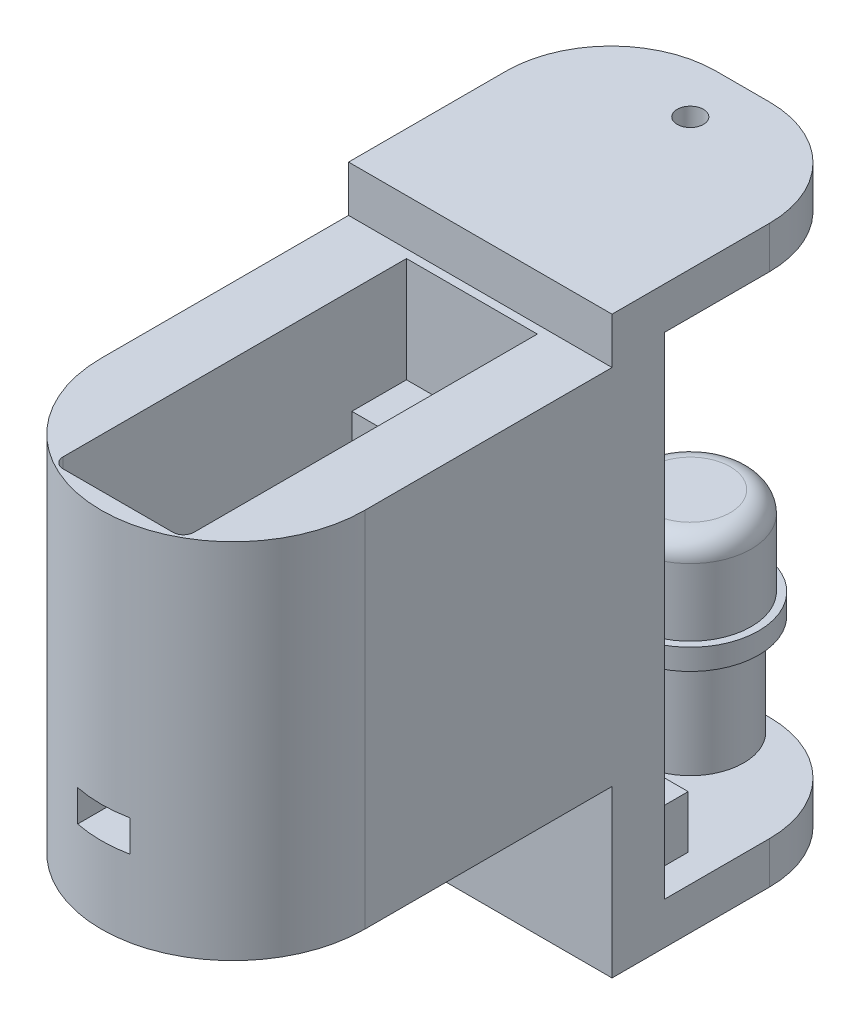
from build123d import *

# Parameters (mm, degrees)
SKETCH4_W                = 12.46
SKETCH4_H                = 17.25
BOSS_EXTRUDE3_DEPTH      = 6
SKETCH8_R                = 12.546781182
SKETCH8_R_2              = 11.15
BOSS_EXTRUDE6_DEPTH      = 7.3
BOSS_EXTRUDE6_DEPTH_BACK = 17.25
BOSS_EXTRUDE4_DEPTH      = 17.25
SKETCH6_R                = 0.5
CUT_EXTRUDE1_DEPTH       = 15
CHAMFER1_SIZE            = 0.5
CHAMFER1_SIZE2           = 0.866025404
SKETCH10_W               = 12.46
SKETCH10_H               = 23.7
CUT_EXTRUDE3_DEPTH       = 17.25
CUT_EXTRUDE4_REACH       = 38.097
SKETCH11_W               = 5
SKETCH11_H               = 3
BOSS_EXTRUDE7_DEPTH      = 7.3
BOSS_EXTRUDE9_DEPTH      = 10
SKETCH20_R               = 11.15
SKETCH20_R_2             = 7.15
BOSS_EXTRUDE11_DEPTH     = 7.3
SKETCH21_R               = 10.15
SKETCH21_R_2             = 7.15
CUT_EXTRUDE7_DEPTH       = 1.3
BOSS_EXTRUDE10_DEPTH     = 25.093562
SKETCH18_W               = 20
SKETCH18_H               = 12.438292938
CUT_EXTRUDE5_DEPTH       = 2
SKETCH19_R               = 1.25
CUT_EXTRUDE6_DEPTH       = 53.75
CUT_EXTRUDE6_DEPTH_BACK  = 3
FILLET1_R                = 10
SKETCH22_R               = 5.8
BOSS_EXTRUDE12_DEPTH     = 20
FILLET2_R                = 2
SKETCH23_R               = 5.930854157
SKETCH23_R_2             = 5.08
CUT_EXTRUDE8_DEPTH       = 11.6
SKETCH24_R               = 6.5
BOSS_EXTRUDE13_DEPTH     = 2
SKETCH25_R               = 1.25
BOSS_EXTRUDE14_DEPTH     = 2
SKETCH26_W               = 5
SKETCH26_H               = 3
BOSS_EXTRUDE15_DEPTH     = 5


with BuildPart() as part:
    # Sketch4 → Boss-Extrude3 (new body)
    with BuildSketch(Plane.XY):
        with Locations((0, -1.35)):
            Rectangle(SKETCH4_W, SKETCH4_H)
    extrude(amount=BOSS_EXTRUDE3_DEPTH)



with BuildPart() as body_2:
    # Sketch8 → Boss-Extrude6 (new body, two sides)
    with BuildSketch(Plane(origin=(0, -9.975, 0), x_dir=(-1, 0, 0), z_dir=(0, -1, 0))) as boss_extrude6_sk:
        with Locations((0, -23.55)):
            Circle(SKETCH8_R)
        with Locations((0, -23.55)):
            Circle(SKETCH8_R_2, mode=Mode.SUBTRACT)
    extrude(amount=BOSS_EXTRUDE6_DEPTH)
    extrude(boss_extrude6_sk.sketch, amount=-BOSS_EXTRUDE6_DEPTH_BACK)


with BuildPart() as part_1:
    add(part.part)

    add(body_2.part)  # Boss-Extrude4 merges body 2
    # Sketch5 → Boss-Extrude4 (add)
    with BuildSketch(Plane(origin=(0, 7.275, 0), x_dir=(1, 0, 0), z_dir=(0, 1, 0))):
        with BuildLine():
            Line((12.546781182, -23.55), (12.546781182, 0))
            Line((12.546781182, 0), (6.23, 0))
            Line((6.23, 0), (6.23, -29.7))
            Line((6.23, -29.7), (-6.23, -29.7))
            Line((-6.23, -29.7), (-6.23, 0))
            Line((-6.23, 0), (-12.546781182, 0))
            Line((-12.546781182, 0), (-12.546781182, -23.55))
            ThreePointArc((-12.546781182, -23.55), (0, -36.096781182), (12.546781182, -23.55))
        make_face()
    extrude(amount=-BOSS_EXTRUDE4_DEPTH)

    # Sketch6 → Cut-Extrude1 (cut)
    with BuildSketch(Plane(origin=(0, 7.275, 0), x_dir=(1, 0, 0), z_dir=(0, 1, 0))):
        with Locations((0, -3.6)):
            Circle(SKETCH6_R)
        with Locations((0, -32.1)):
            Circle(SKETCH6_R)
    extrude(amount=-CUT_EXTRUDE1_DEPTH, mode=Mode.SUBTRACT)

    # Chamfer1
    chamfer1_edges = [part_1.edges().sort_by_distance(p)[0] for p in [
        (-0.5, 7.275, 3.6),
        (-0.5, 7.275, 32.1),
    ]]
    chamfer1_side = [part_1.faces().sort_by_distance(p)[0] for p in [
        (0, 7.275, 35.657160381),
    ]]
    chamfer(chamfer1_edges, length=CHAMFER1_SIZE, length2=CHAMFER1_SIZE2, reference=chamfer1_side[0])

    # Sketch10 → Cut-Extrude3 (cut)
    with BuildSketch(Plane(origin=(0, 7.275, 0), x_dir=(1, 0, 0), z_dir=(0, 1, 0))):
        with Locations((0, -17.85)):
            Rectangle(SKETCH10_W, SKETCH10_H)
    extrude(amount=-CUT_EXTRUDE3_DEPTH, mode=Mode.SUBTRACT)

    # Sketch11 → Cut-Extrude4 (cut, up to next)
    with BuildSketch(Plane.XY.offset(36.096781182), mode=Mode.PRIVATE) as cut_extrude4_sk1:
        with Locations((0, -8.475)):
            Rectangle(SKETCH11_W, SKETCH11_H)
    cut_extrude4_tool1 = extrude(cut_extrude4_sk1.sketch, amount=-CUT_EXTRUDE4_REACH, mode=Mode.PRIVATE) & part_1.part
    add(cut_extrude4_tool1.solids().sort_by_distance((0, -8.475, 36.096781))[0], mode=Mode.SUBTRACT)

    # Sketch13 → Boss-Extrude7 (add)
    with BuildSketch(Plane.XZ.offset(17.275)):
        with BuildLine():
            Line((-12.546781182, 23.55), (-12.546781182, 0))
            Line((-12.546781182, 0), (12.546781182, 0))
            Line((12.546781182, 0), (12.546781182, 23.55))
            ThreePointArc((12.546781182, 23.55), (0, 11.003218818), (-12.546781182, 23.55))
        make_face()
    extrude(amount=-BOSS_EXTRUDE7_DEPTH)

    # Sketch15 → Boss-Extrude9 (add)
    with BuildSketch(Plane(origin=(0, 7.275, 0), x_dir=(1, 0, 0), z_dir=(0, 1, 0))):
        with BuildLine():
            Line((-12.546781182, 0), (12.546781182, 0))
            Line((12.546781182, 0), (12.546781182, -23.55))
            ThreePointArc((12.546781182, -23.55), (0, -36.096781182), (-12.546781182, -23.55))
            Line((-12.546781182, -23.55), (-12.546781182, 0))
        make_face()
        with BuildLine():
            Line((-6.23, -0.8), (6.23, -0.8))
            Line((6.23, -0.8), (6.23, -33.5))
            ThreePointArc((6.23, -33.5), (5.937106781, -34.207106781), (5.23, -34.5))
            Line((5.23, -34.5), (-5.23, -34.5))
            ThreePointArc((-5.23, -34.5), (-5.937106781, -34.207106781), (-6.23, -33.5))
            Line((-6.23, -33.5), (-6.23, -0.8))
        make_face(mode=Mode.SUBTRACT)
    extrude(amount=BOSS_EXTRUDE9_DEPTH)

    # Sketch20 → Boss-Extrude11 (add)
    with BuildSketch(Plane.XZ.offset(17.275)):
        with Locations((0, 23.55)):
            Circle(SKETCH20_R)
        with Locations((0, 23.55)):
            Circle(SKETCH20_R_2, mode=Mode.SUBTRACT)
    extrude(amount=-BOSS_EXTRUDE11_DEPTH)

    # Sketch21 → Cut-Extrude7 (cut)
    with BuildSketch(Plane.XZ.offset(17.275)):
        with Locations((0, 23.55)):
            Circle(SKETCH21_R)
        with Locations((0, 23.55)):
            Circle(SKETCH21_R_2, mode=Mode.SUBTRACT)
    extrude(amount=-CUT_EXTRUDE7_DEPTH, mode=Mode.SUBTRACT)

    # Sketch17 → Boss-Extrude10 (add)
    with BuildSketch(Plane(origin=(12.546781182, 4.728218818, 0), x_dir=(0, 1, 0), z_dir=(-1, 0, 0))):
        Polygon((16.946781182, 25), (16.946781182, 0), (-37.803218818, 0), (-37.803218818, 25), (-33.803218818, 25), (-33.803218818, 5), (12.946781182, 5), (12.946781182, 25), align=None)
    extrude(amount=BOSS_EXTRUDE10_DEPTH)

    # Sketch18 → Cut-Extrude5 (cut)
    with BuildSketch(Plane(origin=(0, 17.675, 0), x_dir=(0, 0, 1), z_dir=(0, -1, 0))):
        with Locations((-15, 0)):
            Rectangle(SKETCH18_W, SKETCH18_H)
    extrude(amount=-CUT_EXTRUDE5_DEPTH, mode=Mode.SUBTRACT)

    # Sketch19 → Cut-Extrude6 (cut, two sides)
    with BuildSketch(Plane(origin=(0, 19.675, 0), x_dir=(0, 0, 1), z_dir=(0, -1, 0))) as cut_extrude6_sk:
        with Locations((-20, 0)):
            Circle(SKETCH19_R)
    extrude(amount=CUT_EXTRUDE6_DEPTH, mode=Mode.SUBTRACT)
    extrude(cut_extrude6_sk.sketch, amount=-CUT_EXTRUDE6_DEPTH_BACK, mode=Mode.SUBTRACT)

    # Fillet1
    fillet1_edges = [part_1.edges().sort_by_distance(p)[0] for p in [
        (-12.546780818, 19.675, -25),
        (12.546781182, 19.675, -25),
        (-12.546780818, -31.075, -25),
        (12.546781182, -31.075, -25),
    ]]
    fillet(fillet1_edges, radius=FILLET1_R)

    # Sketch22 → Boss-Extrude12 (add)
    with BuildSketch(Plane(origin=(0, -29.075, 0), x_dir=(0, 0, -1), z_dir=(0, 1, 0))):
        with Locations((20, 0)):
            Circle(SKETCH22_R)
    extrude(amount=BOSS_EXTRUDE12_DEPTH)

    # Fillet2
    fillet2_edges = [part_1.edges().sort_by_distance(p)[0] for p in [
        (0, -9.075, -14.2),
    ]]
    fillet(fillet2_edges, radius=FILLET2_R)

    # Sketch23 → Cut-Extrude8 (cut)
    with BuildSketch(Plane(origin=(0, -29.075, 0), x_dir=(0, 0, -1), z_dir=(0, 1, 0))):
        with Locations((20, 0)):
            Circle(SKETCH23_R)
        with Locations((20, 0)):
            Circle(SKETCH23_R_2, mode=Mode.SUBTRACT)
    extrude(amount=CUT_EXTRUDE8_DEPTH, mode=Mode.SUBTRACT)

    # Sketch24 → Boss-Extrude13 (add)
    with BuildSketch(Plane(origin=(0, -17.475, 0), x_dir=(0, 0, 1), z_dir=(0, -1, 0))):
        with Locations((-20, 0)):
            Circle(SKETCH24_R)
    extrude(amount=BOSS_EXTRUDE13_DEPTH)

    # Sketch25 → Boss-Extrude14 (add)
    with BuildSketch(Plane(origin=(0, -33.075, 0), x_dir=(0, 0, 1), z_dir=(0, -1, 0))):
        with Locations((-20, 0)):
            Circle(SKETCH25_R)
    extrude(amount=-BOSS_EXTRUDE14_DEPTH)

    # Sketch26 → Boss-Extrude15 (add)
    with BuildSketch(Plane(origin=(0, -29.075, 0), x_dir=(0, 0, -1), z_dir=(0, 1, 0))):
        with Locations((7.5, -8.296781182)):
            Rectangle(SKETCH26_W, SKETCH26_H)
        with Locations((7.5, -3.780781182)):
            Rectangle(SKETCH26_W, SKETCH26_H)
    extrude(amount=BOSS_EXTRUDE15_DEPTH)


solid = part_1.part
